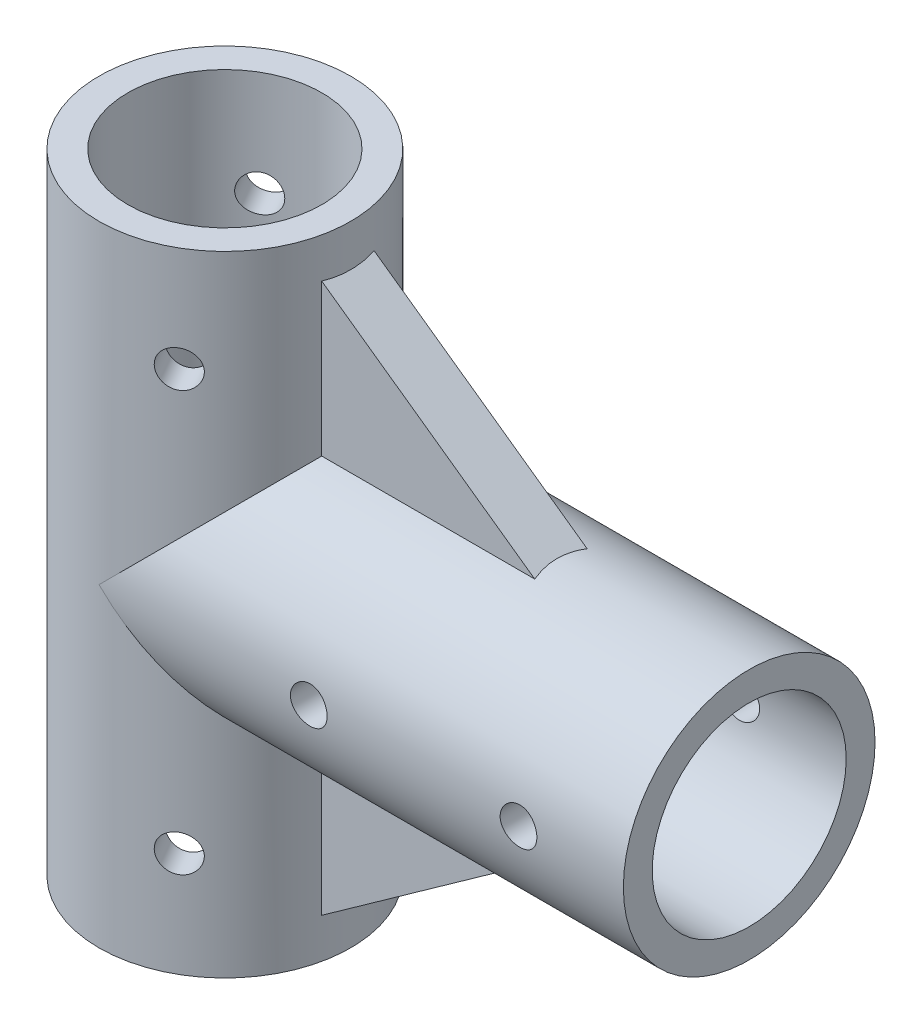
from build123d import *

# Parameters (mm, degrees)
SKETCH_1_R               = 12
SKETCH_1_R_2             = 9.25
EXTRUDE_1_DEPTH          = 30
EXTRUDE_2_REACH          = 86.467
EXTRUDE_START            = 50
SKETCH_2_R               = 12
SKETCH_2_R_2             = 9.25
CUT_EXTRUDE_1_DEPTH      = 60.531504349
CUT_EXTRUDE_1_DEPTH_BACK = 60.531504349
SKETCH_3_R               = 1.75
CUT_EXTRUDE_2_DEPTH      = 60.531504419
CUT_EXTRUDE_2_DEPTH_BACK = 60.531504419
SKETCH_4_R               = 1.75
EXTRUDE_3_DEPTH          = 2.5
CUT_EXTRUDE_3_REACH      = 71.914
CUT_EXTRUDE_3_END_RADIUS = 9.25
SKETCH_6_R               = 9.25


with BuildPart() as part:
    # ｽｹｯﾁ1 → ﾎﾞｽ - 押し出し1 (new, symmetric)
    with BuildSketch(Plane(origin=(0, 0, 0), x_dir=(1, 0, 0), z_dir=(0, 1, 0))):
        Circle(SKETCH_1_R)
        Circle(SKETCH_1_R_2, mode=Mode.SUBTRACT)
    extrude(amount=EXTRUDE_1_DEPTH, both=True)

    # ｽｹｯﾁ2 → ﾎﾞｽ - 押し出し2 (add, up to next)
    with BuildSketch(Plane(origin=(0, 0, 0), x_dir=(0, 0, -1), z_dir=(1, 0, 0)).offset(EXTRUDE_START), mode=Mode.PRIVATE) as extrude_2_sk1:
        Circle(SKETCH_2_R)
        Circle(SKETCH_2_R_2, mode=Mode.SUBTRACT)
    extrude_2_tool1 = extrude(extrude_2_sk1.sketch, amount=-EXTRUDE_2_REACH, mode=Mode.PRIVATE) - part.part
    add(extrude_2_tool1.solids().sort_by_distance((50, 0, 11.660589))[0])

    # ｽｹｯﾁ3 → ｶｯﾄ - 押し出し1 (cut, two sides: drawn at the far end of the back side and taken through both)
    with BuildSketch(Plane(origin=(0, 0, 0), x_dir=(0, -1, 0), z_dir=(0.499999999999998, 0, 0.8660254037844398)).offset(-CUT_EXTRUDE_1_DEPTH_BACK)):
        with Locations((-20, 0)):
            Circle(SKETCH_3_R)
        with Locations((20, 0)):
            Circle(SKETCH_3_R)
    extrude(amount=CUT_EXTRUDE_1_DEPTH + CUT_EXTRUDE_1_DEPTH_BACK, mode=Mode.SUBTRACT)

    # ｽｹｯﾁ4 → ｶｯﾄ - 押し出し2 (cut, two sides: drawn at the far end of the back side and taken through both)
    with BuildSketch(Plane.XY.offset(-CUT_EXTRUDE_2_DEPTH_BACK)):
        with Locations((20, 0)):
            Circle(SKETCH_4_R)
        with Locations((40, 0)):
            Circle(SKETCH_4_R)
    extrude(amount=CUT_EXTRUDE_2_DEPTH + CUT_EXTRUDE_2_DEPTH_BACK, mode=Mode.SUBTRACT)

    # ｽｹｯﾁ5 → ﾎﾞｽ - 押し出し3 (add, symmetric)
    with BuildSketch(Plane.XY):
        Polygon((10.496083989, 27.069423811), (33.248789053, 10.881728509), (10.496083989, 10.496083989), align=None)
        Polygon((33.248789053, -10.881728509), (10.496083989, -10.496083989), (10.496083989, -27.069423811), align=None)
    extrude(amount=EXTRUDE_3_DEPTH, both=True)

    # ｶｯﾄ - 押し出し3: up to this cylinder (the profile starts outside it)
    cut_extrude_3_end = Plane(origin=(0, 0, 0), z_dir=(0, -1, 0)) * Cylinder(CUT_EXTRUDE_3_END_RADIUS, 163.328, mode=Mode.PRIVATE)
    # ｽｹｯﾁ6 → ｶｯﾄ - 押し出し3 (cut, up to the surface)
    with BuildSketch(Plane(origin=(50, 0, 0), x_dir=(0, 0, -1), z_dir=(1, 0, 0)), mode=Mode.PRIVATE) as cut_extrude_3_sk1:
        Circle(SKETCH_6_R)
    cut_extrude_3_tool1 = extrude(cut_extrude_3_sk1.sketch, amount=-CUT_EXTRUDE_3_REACH, mode=Mode.PRIVATE) - cut_extrude_3_end
    add(cut_extrude_3_tool1.solids().sort_by_distance((50, 0, 0))[0], mode=Mode.SUBTRACT)


solid = part.part
